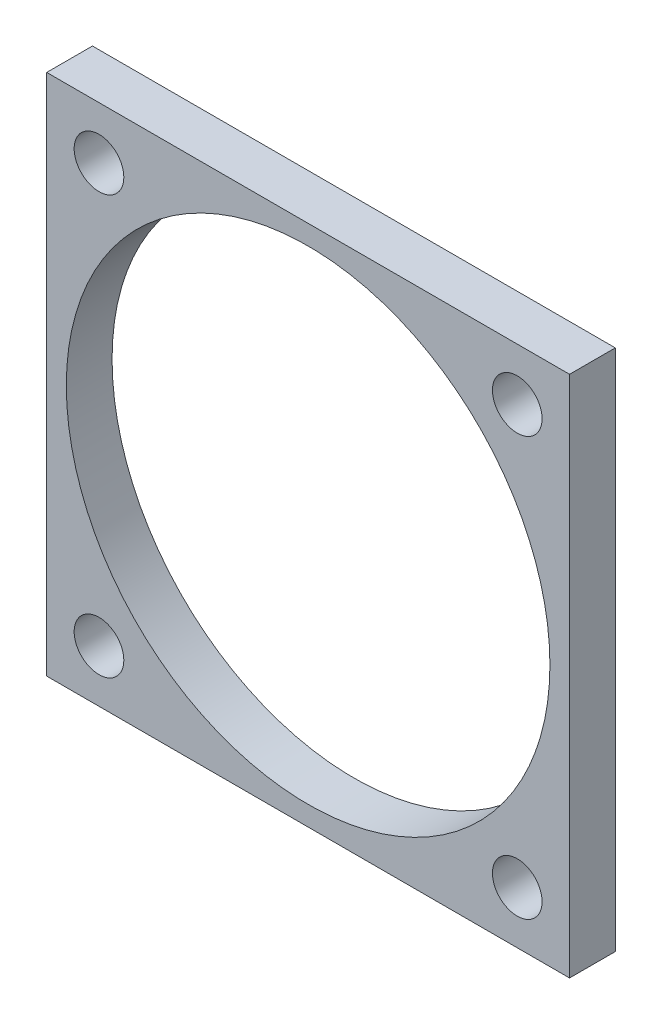
from build123d import *

# Parameters (mm, degrees)
SKETCH1_W           = 40
SKETCH1_H           = 40
SKETCH1_R           = 1.9
SKETCH1_R_2         = 18.5
BOSS_EXTRUDE1_DEPTH = 3.5


with BuildPart() as part:
    # Sketch1 → Boss-Extrude1 (new body)
    with BuildSketch(Plane.XY):
        with Locations((20, -20)):
            Rectangle(SKETCH1_W, SKETCH1_H)
        with Locations((4, -4)):
            Circle(SKETCH1_R, mode=Mode.SUBTRACT)
        with Locations((36, -4)):
            Circle(SKETCH1_R, mode=Mode.SUBTRACT)
        with Locations((36, -36)):
            Circle(SKETCH1_R, mode=Mode.SUBTRACT)
        with Locations((4, -36)):
            Circle(SKETCH1_R, mode=Mode.SUBTRACT)
        with Locations((20, -20)):
            Circle(SKETCH1_R_2, mode=Mode.SUBTRACT)
    extrude(amount=BOSS_EXTRUDE1_DEPTH)


solid = part.part
